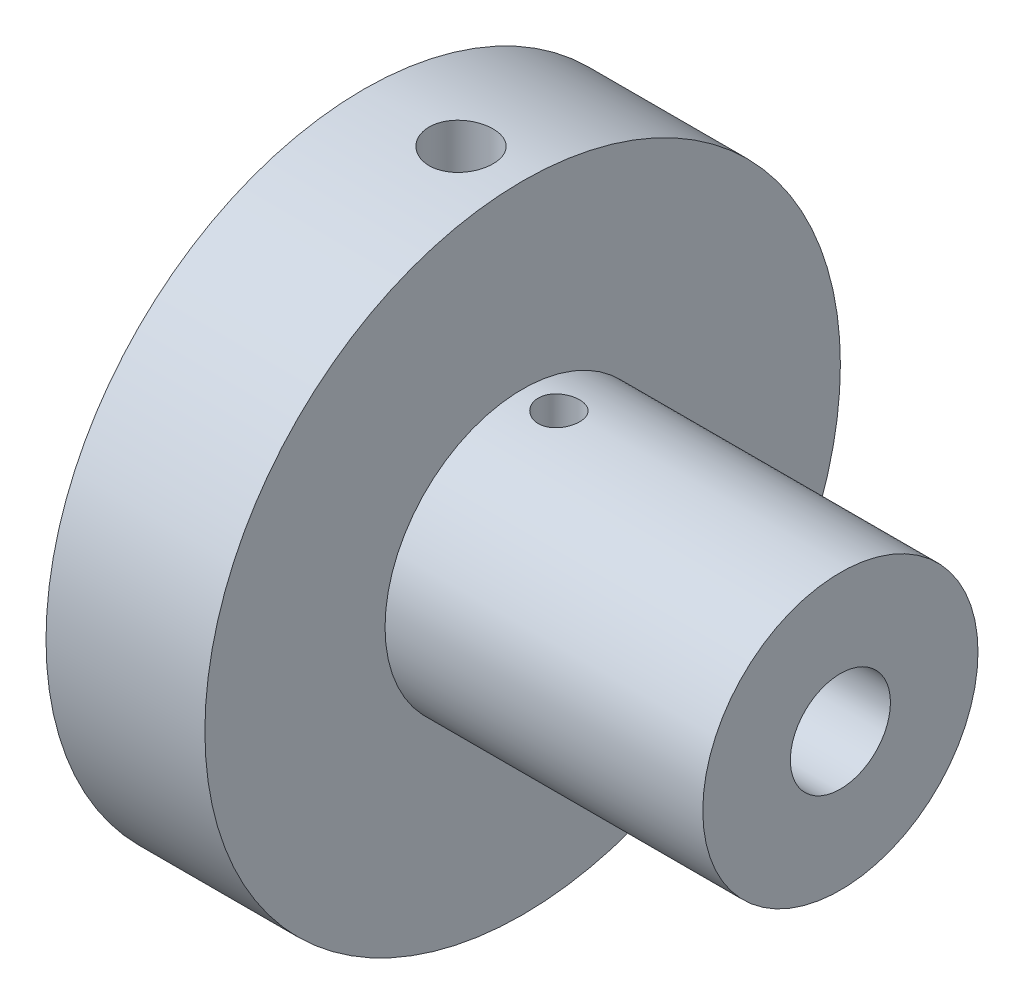
from build123d import *

# Parameters (mm, degrees)
SKETCH2_R                 = 11
BOSS_EXTRUDE2_DEPTH       = 25.4
SKETCH7_R                 = 4
CUT_EXTRUDE3_DEPTH        = 26.4
SKETCH8_R                 = 25.4
BOSS_EXTRUDE3_DEPTH       = 12.7
SKETCH10_R                = 4
CUT_EXTRUDE5_DEPTH        = 13.7
F_1_4_20_TAPPED_HOLE1_D   = 5.1054
M4X0_7_TAPPED_HOLE2_D     = 3.3
M4X0_7_TAPPED_HOLE2_DEPTH = 11.176
M4X0_7_TAPPED_HOLE2_TIP   = 0.991420021


with BuildPart() as part:
    # Sketch2 → Boss-Extrude2 (new body)
    with BuildSketch(Plane(origin=(0, 0, 0), x_dir=(0, 0, -1), z_dir=(1, 0, 0))):
        Circle(SKETCH2_R)
    extrude(amount=BOSS_EXTRUDE2_DEPTH)

    # Sketch7 → Cut-Extrude3 (cut, through all)
    with BuildSketch(Plane(origin=(25.4, 0, 0), x_dir=(0, 0, -1), z_dir=(1, 0, 0))):
        Circle(SKETCH7_R)
    extrude(amount=-CUT_EXTRUDE3_DEPTH, mode=Mode.SUBTRACT)

    # Sketch8 → Boss-Extrude3 (add)
    with BuildSketch(Plane.ZY):
        Circle(SKETCH8_R)
    extrude(amount=BOSS_EXTRUDE3_DEPTH)

    # Sketch10 → Cut-Extrude5 (cut, through all)
    with BuildSketch(Plane(origin=(0, 0, 0), x_dir=(0, 0, -1), z_dir=(1, 0, 0))):
        Circle(SKETCH10_R)
    extrude(amount=-CUT_EXTRUDE5_DEPTH, mode=Mode.SUBTRACT)

    # 1/4-20 Tapped Hole1 (through all)
    with Locations(Plane(origin=(-4.921208149, 25.4, 0), x_dir=(0, 0, 1), z_dir=(0, 1, 0))):
        with Locations((0, 0)):
            Hole(F_1_4_20_TAPPED_HOLE1_D / 2)

    # M4x0.7 Tapped Hole2
    with Locations(Plane(origin=(2.900798662, 11, 0), x_dir=(0, 0, 1), z_dir=(0, 1, 0))):
        with Locations((0, 0)):
            Hole(M4X0_7_TAPPED_HOLE2_D / 2, depth=M4X0_7_TAPPED_HOLE2_DEPTH)
            with Locations((0, 0, -(M4X0_7_TAPPED_HOLE2_DEPTH + M4X0_7_TAPPED_HOLE2_TIP / 2))):  # 118° drill point
                Cone(0, M4X0_7_TAPPED_HOLE2_D / 2, M4X0_7_TAPPED_HOLE2_TIP, mode=Mode.SUBTRACT)


solid = part.part
